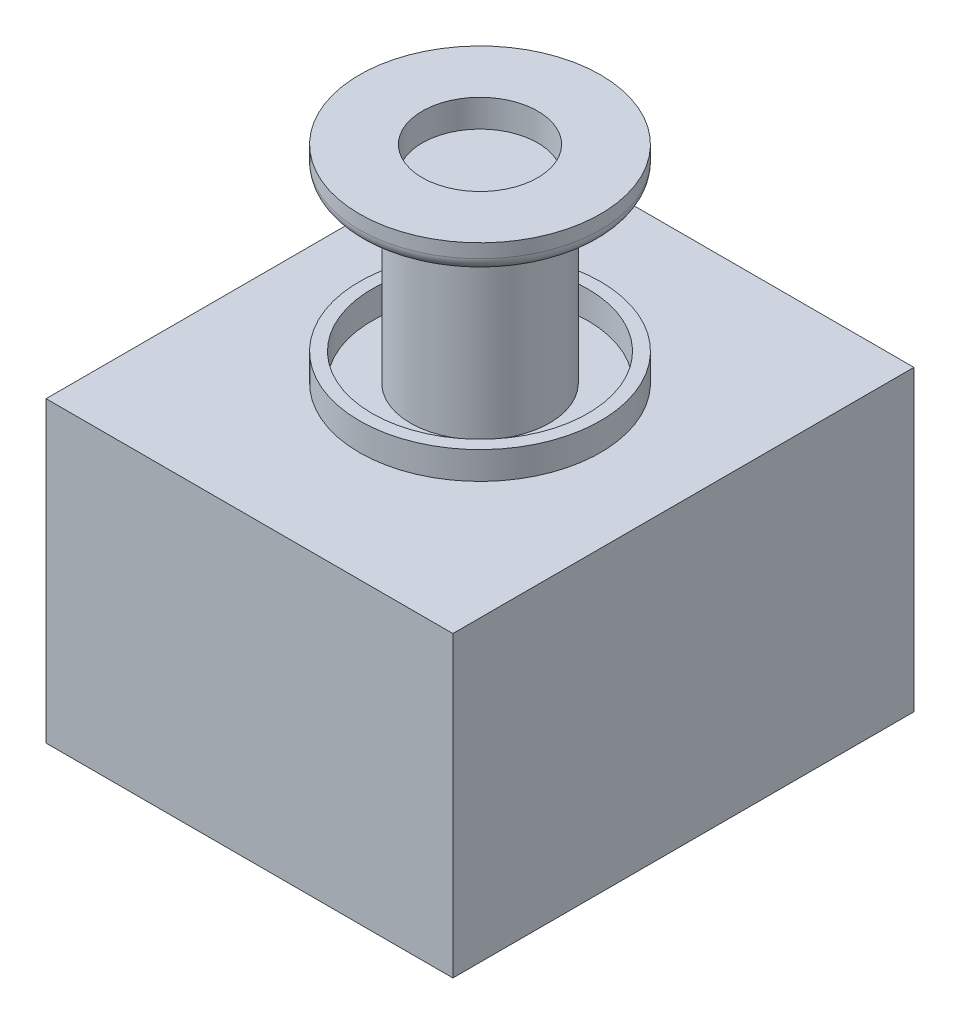
from build123d import *

# Parameters (mm, degrees)
SKETCH1_W           = 75
SKETCH1_H           = 85
BOSS_EXTRUDE1_DEPTH = 55
SKETCH2_R           = 22.225
BOSS_EXTRUDE2_DEPTH = 5.08
SKETCH3_2_R         = 19.890557265
CUT_EXTRUDE1_DEPTH  = 5.08
SKETCH4_R           = 12.819708226
BOSS_EXTRUDE4_DEPTH = 33.02
SKETCH5_R           = 22.225
BOSS_EXTRUDE5_DEPTH = 5.08
FILLET1_R           = 2.54
SKETCH6_R           = 10.645057699
CUT_EXTRUDE2_DEPTH  = 5.08


with BuildPart() as part:
    # Sketch1 → Boss-Extrude1 (new body)
    with BuildSketch(Plane(origin=(0, 0, 0), x_dir=(1, 0, 0), z_dir=(0, 1, 0))):
        Rectangle(SKETCH1_W, SKETCH1_H)
    extrude(amount=BOSS_EXTRUDE1_DEPTH)

    # Sketch2 → Boss-Extrude2 (add)
    with BuildSketch(Plane(origin=(0, 55, 0), x_dir=(1, 0, 0), z_dir=(0, 1, 0))):
        Circle(SKETCH2_R)
    extrude(amount=BOSS_EXTRUDE2_DEPTH)

    # Sketch3_2 → Cut-Extrude1 (cut)
    with BuildSketch(Plane(origin=(0, 60.08, 0), x_dir=(1, 0, 0), z_dir=(0, 1, 0))):
        Circle(SKETCH3_2_R)
    extrude(amount=-CUT_EXTRUDE1_DEPTH, mode=Mode.SUBTRACT)

    # Sketch4 → Boss-Extrude4 (add)
    with BuildSketch(Plane(origin=(0, 55, 0), x_dir=(1, 0, 0), z_dir=(0, 1, 0))):
        Circle(SKETCH4_R)
    extrude(amount=BOSS_EXTRUDE4_DEPTH)

    # Sketch5 → Boss-Extrude5 (add)
    with BuildSketch(Plane(origin=(0, 88.02, 0), x_dir=(1, 0, 0), z_dir=(0, 1, 0))):
        Circle(SKETCH5_R)
    extrude(amount=BOSS_EXTRUDE5_DEPTH)

    # Fillet1
    fillet1_edges = [part.edges().sort_by_distance(p)[0] for p in [
        (-22.225, 88.02, 0),
        (-12.819708226, 88.02, 0),
    ]]
    fillet(fillet1_edges, radius=FILLET1_R)

    # Sketch6 → Cut-Extrude2 (cut)
    with BuildSketch(Plane(origin=(0, 93.1, 0), x_dir=(1, 0, 0), z_dir=(0, 1, 0))):
        Circle(SKETCH6_R)
    extrude(amount=-CUT_EXTRUDE2_DEPTH, mode=Mode.SUBTRACT)


solid = part.part
